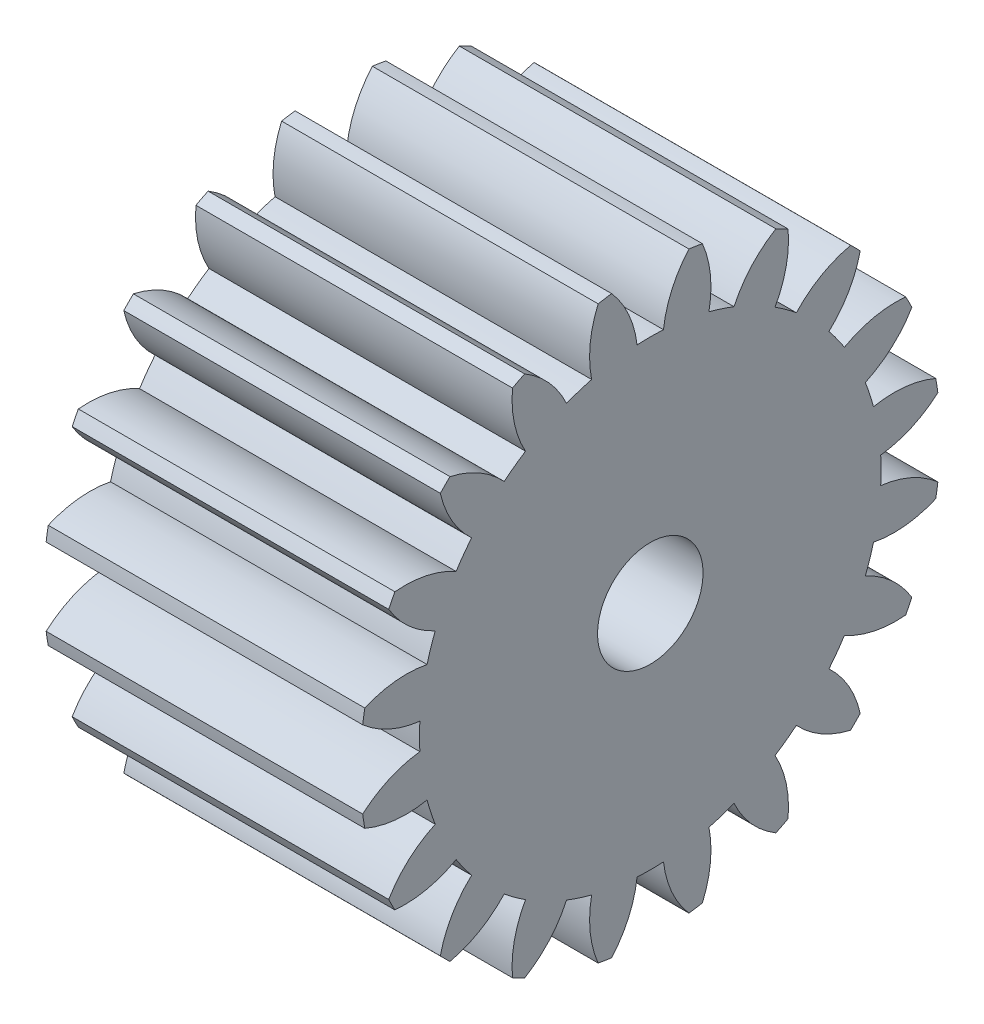
from build123d import *

# Parameters (mm, degrees)
BASPROSKE_W     = 12
BASPROSKE_H     = 11
TOOTHCUT_DEPTH  = 20.646882704
TEETHCUTS_COUNT = 20
TEETHCUTS_ANGLE = 342
BORSKE_R        = 2
BORE_DEPTH      = 50.0000508


with BuildPart() as part:
    # BasProSke → Base-Revolve (revolve)
    with BuildSketch(Plane(origin=(0, 0, 0), x_dir=(1, 0, 0), z_dir=(0, 1, 0)), mode=Mode.PRIVATE) as base_revolve_sk:
        with Locations((6, 5.5)):
            Rectangle(BASPROSKE_W, BASPROSKE_H)
    revolve(base_revolve_sk.sketch.rotate(Axis((-10, 0, 0), (1, 0, 0)), 180), axis=Axis((-10, 0, 0), (1, 0, 0)))

    # TooCutSke → ToothCut (cut, through all)
    with BuildSketch(Plane(origin=(0, 0, 0), x_dir=(0, 0, -1), z_dir=(1, 0, 0))):
        with BuildLine():
            ThreePointArc((0.499924007, 8.734705318), (0, 8.749), (-0.499924007, 8.734705318))
            ThreePointArc((-0.499924007, 8.734705318), (-0.824302243, 9.905497836), (-1.485192705, 10.924909509))
            ThreePointArc((-1.485192705, 10.924909509), (0, 11.0254), (1.485192705, 10.924909509))
            ThreePointArc((1.485192705, 10.924909509), (0.824302243, 9.905497836), (0.499924007, 8.734705318))
        make_face()
    toothcut = extrude(amount=TOOTHCUT_DEPTH, mode=Mode.SUBTRACT)

    # TeethCuts: ToothCut ×20 about axis
    teethcuts_axis = Axis((-10, 0, 0), (1, 0, 0))
    for i in range(1, TEETHCUTS_COUNT):
        add(toothcut.rotate(teethcuts_axis, i * TEETHCUTS_ANGLE / (TEETHCUTS_COUNT - 1)), mode=Mode.SUBTRACT)

    # BorSke → Bore (cut, symmetric)
    with BuildSketch(Plane(origin=(0, 0, 0), x_dir=(0, 0, -1), z_dir=(1, 0, 0))):
        with Locations(Location((0, 0, 0), (0, 0, 180))):
            Circle(BORSKE_R)
    extrude(amount=BORE_DEPTH, both=True, mode=Mode.SUBTRACT)


solid = part.part
